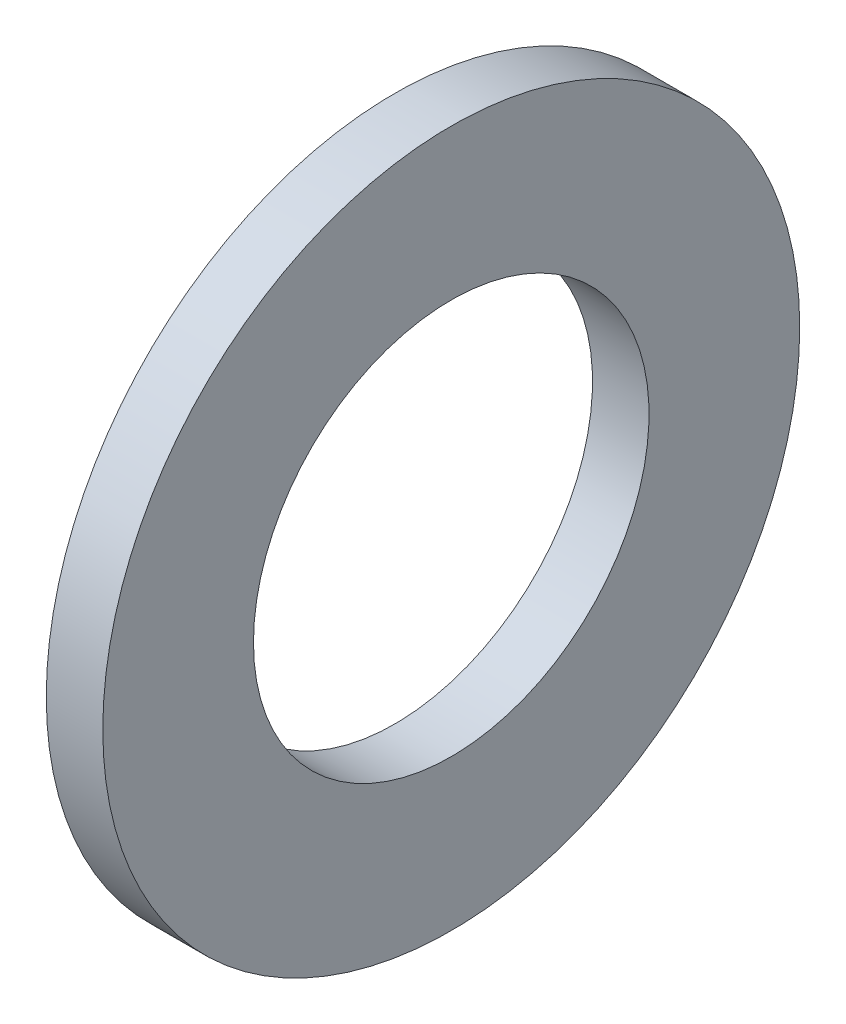
from build123d import *

# Parameters (mm, degrees)
SKETCH1_W = 3
SKETCH1_H = 8


with BuildPart() as part:
    # Sketch1 → Base-Revolve (revolve)
    with BuildSketch(Plane.XY):
        with Locations((-1.5, 14.5)):
            Rectangle(SKETCH1_W, SKETCH1_H)
    revolve(axis=Axis((-34.925, 0, 0), (1, 0, 0)))


solid = part.part
